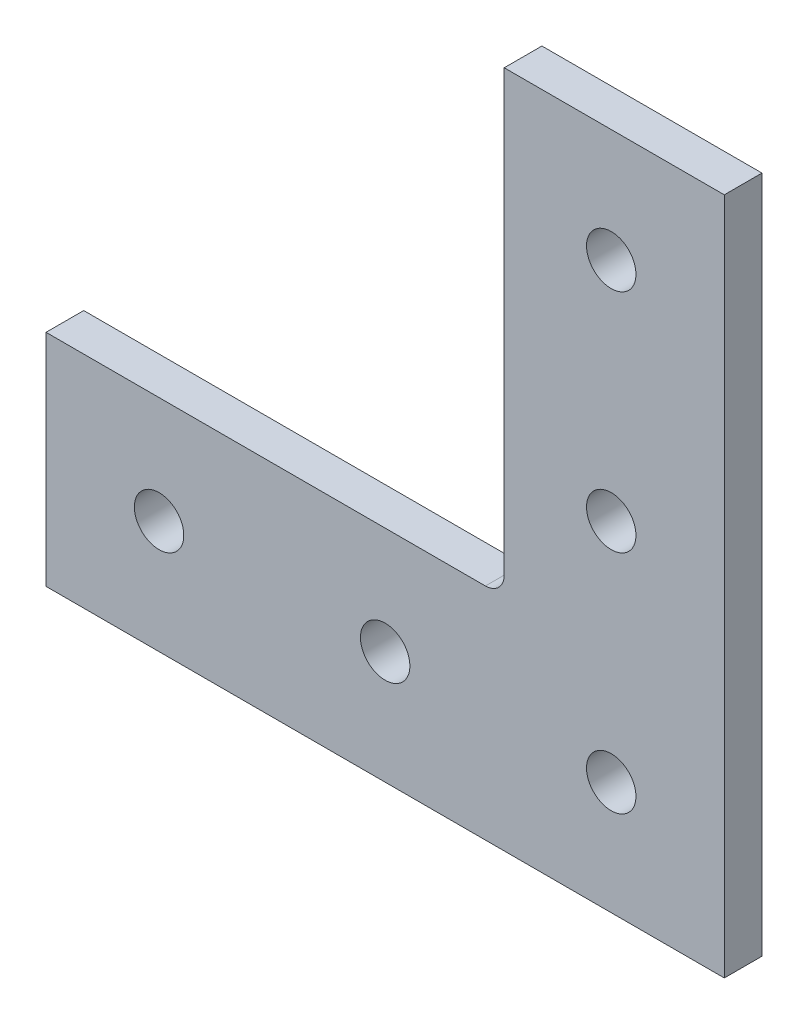
from build123d import *

# Parameters (mm, degrees)
SKETCH1_R           = 4.1656
BOSS_EXTRUDE1_DEPTH = 6.35


with BuildPart() as part:
    # Sketch1 → Boss-Extrude1 (new body)
    with BuildSketch(Plane.XY.offset(6.35)):
        with BuildLine():
            Line((-40.259, 37.084), (-114.3, 37.084))
            Line((-114.3, 37.084), (-114.3, 0))
            Line((-114.3, 0), (0, 0))
            Line((0, 0), (0, 114.3))
            Line((0, 114.3), (-37.084, 114.3))
            Line((-37.084, 114.3), (-37.084, 40.259))
            ThreePointArc((-37.084, 40.259), (-38.01393597, 38.01393597), (-40.259, 37.084))
        make_face()
        with Locations((-95.25, 19.05)):
            Circle(SKETCH1_R, mode=Mode.SUBTRACT)
        with Locations((-57.15, 19.05)):
            Circle(SKETCH1_R, mode=Mode.SUBTRACT)
        with Locations((-19.05, 57.15)):
            Circle(SKETCH1_R, mode=Mode.SUBTRACT)
        with Locations((-19.05, 95.25)):
            Circle(SKETCH1_R, mode=Mode.SUBTRACT)
        with Locations((-19.05, 19.05)):
            Circle(SKETCH1_R, mode=Mode.SUBTRACT)
    extrude(amount=-BOSS_EXTRUDE1_DEPTH)


solid = part.part
